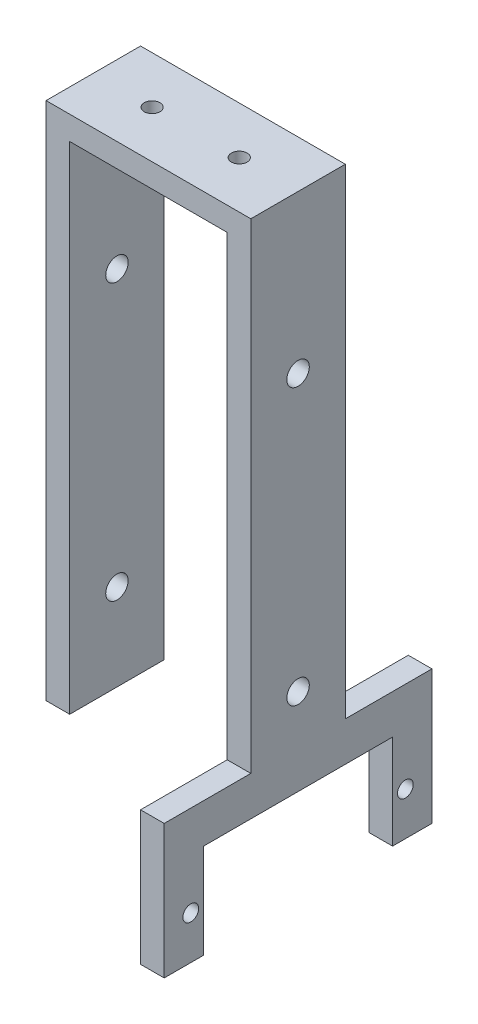
from build123d import *

# Parameters (mm, degrees)
SKETCH2_W           = 26
SKETCH2_H           = 12
BOSS_EXTRUDE1_DEPTH = 3
SKETCH3_R           = 1
CUT_EXTRUDE1_DEPTH  = 10
SKETCH4_W           = 3
SKETCH4_H           = 12
BOSS_EXTRUDE2_DEPTH = 75
SKETCH5_R           = 1.425
CUT_EXTRUDE2_DEPTH  = 30
LPATTERN1_COUNT     = 2
LPATTERN1_PITCH     = 35
BOSS_EXTRUDE3_DEPTH = 3
SKETCH7_R           = 1
CUT_EXTRUDE3_DEPTH  = 3
SKETCH8_W           = 12
SKETCH8_H           = 12
CUT_EXTRUDE4_DEPTH  = 27


with BuildPart() as part:
    # Sketch2 → Boss-Extrude1 (new body)
    with BuildSketch(Plane(origin=(0, 0, 0), x_dir=(1, 0, 0), z_dir=(0, 1, 0))):
        Rectangle(SKETCH2_W, SKETCH2_H)
    extrude(amount=BOSS_EXTRUDE1_DEPTH)

    # Sketch3 → Cut-Extrude1 (cut)
    with BuildSketch(Plane.XZ):
        with Locations((-5.535, 0)):
            Circle(SKETCH3_R)
        with Locations((5.535, 0)):
            Circle(SKETCH3_R)
    extrude(amount=-CUT_EXTRUDE1_DEPTH, mode=Mode.SUBTRACT)

    # Sketch4 → Boss-Extrude2 (add)
    with BuildSketch(Plane.XZ):
        with Locations((-11.5, 0)):
            Rectangle(SKETCH4_W, SKETCH4_H)
    boss_extrude2 = extrude(amount=BOSS_EXTRUDE2_DEPTH)

    # Mirror1: Boss-Extrude2 across plane
    add(boss_extrude2.mirror(Plane(origin=(0, 0, 0), x_dir=(0, 0, 1), z_dir=(1, 0, 0))))

    # Sketch5 → Cut-Extrude2 (cut)
    with BuildSketch(Plane.ZY.offset(13)):
        with Locations((0, -17)):
            Circle(SKETCH5_R)
    cut_extrude2 = extrude(amount=-CUT_EXTRUDE2_DEPTH, mode=Mode.SUBTRACT)

    # LPattern1: Cut-Extrude2 ×2
    with Locations(*[(0, -i * LPATTERN1_PITCH, 0) for i in range(1, LPATTERN1_COUNT)]):
        add(cut_extrude2, mode=Mode.SUBTRACT)

    # Sketch6 → Boss-Extrude3 (add)
    with BuildSketch(Plane(origin=(13, 0, 0), x_dir=(0, 0, -1), z_dir=(1, 0, 0))):
        Polygon((-6, -58), (-17, -58), (-17, -63), (-17, -75), (-12, -75), (-12, -63), (-6, -63), align=None)
    boss_extrude3 = extrude(amount=-BOSS_EXTRUDE3_DEPTH)

    # Mirror2: Boss-Extrude3 across plane
    add(boss_extrude3.mirror(Plane.XY))

    # Sketch7 → Cut-Extrude3 (cut)
    with BuildSketch(Plane(origin=(13, 0, 0), x_dir=(0, 0, -1), z_dir=(1, 0, 0))):
        with Locations((-13.625, -69.526287367)):
            Circle(SKETCH7_R)
    cut_extrude3 = extrude(amount=-CUT_EXTRUDE3_DEPTH, mode=Mode.SUBTRACT)

    # Mirror3: Cut-Extrude3 across plane
    add(cut_extrude3.mirror(Plane.XY), mode=Mode.SUBTRACT)

    # Sketch8 → Cut-Extrude4 (cut, through all)
    with BuildSketch(Plane(origin=(13, 0, 0), x_dir=(0, 0, -1), z_dir=(1, 0, 0))):
        with Locations((0, -69)):
            Rectangle(SKETCH8_W, SKETCH8_H)
    extrude(amount=-CUT_EXTRUDE4_DEPTH, mode=Mode.SUBTRACT)


solid = part.part
